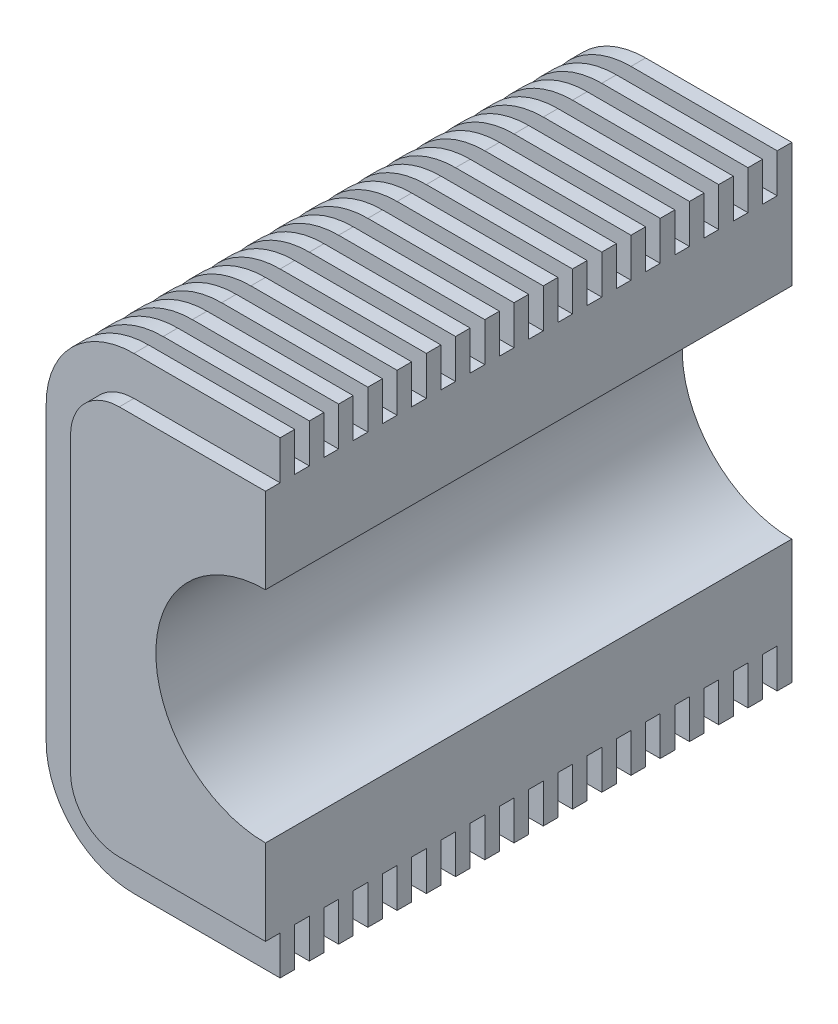
from build123d import *

# Parameters (mm, degrees)
DODANIE_WYCI_GNI_CIE1_DEPTH = 108
DODANIE_WYCI_GNI_CIE2_DEPTH = 3
SZYK_LINIOWY2_COUNT         = 18
SZYK_LINIOWY2_PITCH         = 6
SZKIC2_R                    = 22.5
WYTNIJ_WYCI_GNI_CIE1_DEPTH  = 109


with BuildPart() as part:
    # Szkic1 → Dodanie-wyciągnięcie1 (new body)
    with BuildSketch(Plane.XY):
        with BuildLine():
            Line((0, 75), (-30, 75))
            ThreePointArc((-30, 75), (-37.071067812, 72.071067812), (-40, 65))
            Line((-40, 65), (-40, 5))
            ThreePointArc((-40, 5), (-37.071067812, -2.071067812), (-30, -5))
            Line((-30, -5), (0, -5))
            Line((0, -5), (0, 75))
        make_face()
    extrude(amount=DODANIE_WYCI_GNI_CIE1_DEPTH)

    # Szkic3 → Dodanie-wyciągnięcie2 (add)
    with BuildSketch(Plane(origin=(0, 0, 0), x_dir=(-1, 0, 0), z_dir=(0, 0, -1))):
        with BuildLine():
            Line((0, 75), (30, 75))
            ThreePointArc((30, 75), (37.071067812, 72.071067812), (40, 65))
            Line((40, 65), (40, 5))
            ThreePointArc((40, 5), (37.071067812, -2.071067812), (30, -5))
            Line((30, -5), (0, -5))
            Line((0, -5), (0, -13))
            Line((0, -13), (30, -13))
            ThreePointArc((30, -13), (42.727922061, -7.727922061), (48, 5))
            Line((48, 5), (48, 65))
            ThreePointArc((48, 65), (42.727922061, 77.727922061), (30, 83))
            Line((30, 83), (0, 83))
            Line((0, 83), (0, 75))
        make_face()
    dodanie_wyci_gni_cie2 = extrude(amount=-DODANIE_WYCI_GNI_CIE2_DEPTH)

    # Szyk liniowy2: Dodanie-wyciągnięcie2 ×18
    with Locations(*[(0, 0, i * SZYK_LINIOWY2_PITCH) for i in range(1, SZYK_LINIOWY2_COUNT)]):
        add(dodanie_wyci_gni_cie2)

    # Szkic2 → Wytnij-wyciągnięcie1 (cut, through all)
    with BuildSketch(Plane.XY.offset(108)):
        with Locations((0, 35)):
            Circle(SZKIC2_R)
    extrude(amount=-WYTNIJ_WYCI_GNI_CIE1_DEPTH, mode=Mode.SUBTRACT)


solid = part.part
